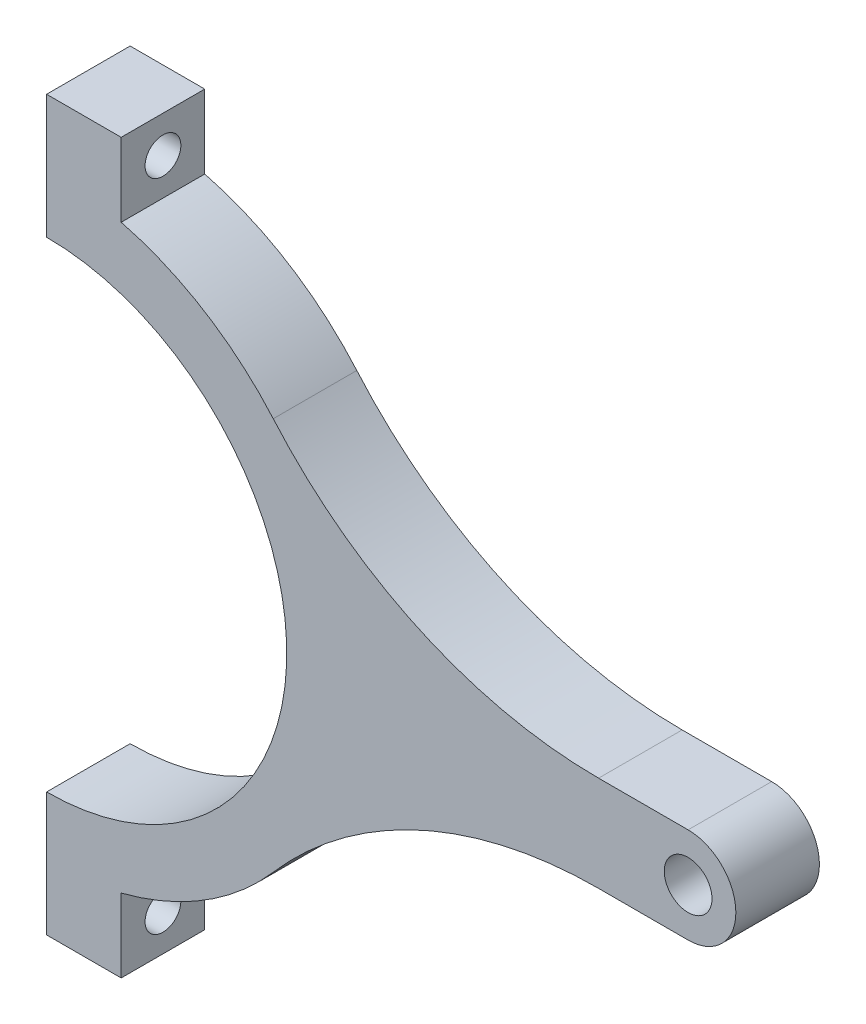
from build123d import *

# Parameters (mm, degrees)
SKETCH1_R           = 8
BOSS_EXTRUDE1_DEPTH = 28
SKETCH2_R           = 6
CUT_EXTRUDE1_DEPTH  = 28


with BuildPart() as part:
    # Sketch1 → Boss-Extrude1 (new body)
    with BuildSketch(Plane.XY):
        with BuildLine():
            Line((0, -122), (0, -80.5))
            ThreePointArc((0, -80.5), (80.5, 0), (0, 80.5))
            Line((0, 80.5), (0, 122))
            Line((0, 122), (25, 122))
            Line((25, 122), (25, 97.340895825))
            ThreePointArc((25, 97.340895825), (52.885741133, 85.459630146), (75.960679556, 65.804446365))
            ThreePointArc((75.960679556, 65.804446365), (125.062415213, 29.040494844), (185, 16))
            Line((185, 16), (215, 16))
            ThreePointArc((215, 16), (231, 0), (215, -16))
            Line((215, -16), (185, -16))
            ThreePointArc((185, -16), (125.062415213, -29.040494844), (75.960679556, -65.804446365))
            ThreePointArc((75.960679556, -65.804446365), (52.885741133, -85.459630146), (25, -97.340895825))
            Line((25, -97.340895825), (25, -122))
            Line((25, -122), (0, -122))
        make_face()
        with Locations((215, 0)):
            Circle(SKETCH1_R, mode=Mode.SUBTRACT)
    extrude(amount=BOSS_EXTRUDE1_DEPTH)

    # Sketch2 → Cut-Extrude1 (cut)
    with BuildSketch(Plane.ZY):
        with Locations((14, 109.7)):
            Circle(SKETCH2_R)
        with Locations((14, -109.7)):
            Circle(SKETCH2_R)
    extrude(amount=-CUT_EXTRUDE1_DEPTH, mode=Mode.SUBTRACT)


solid = part.part
